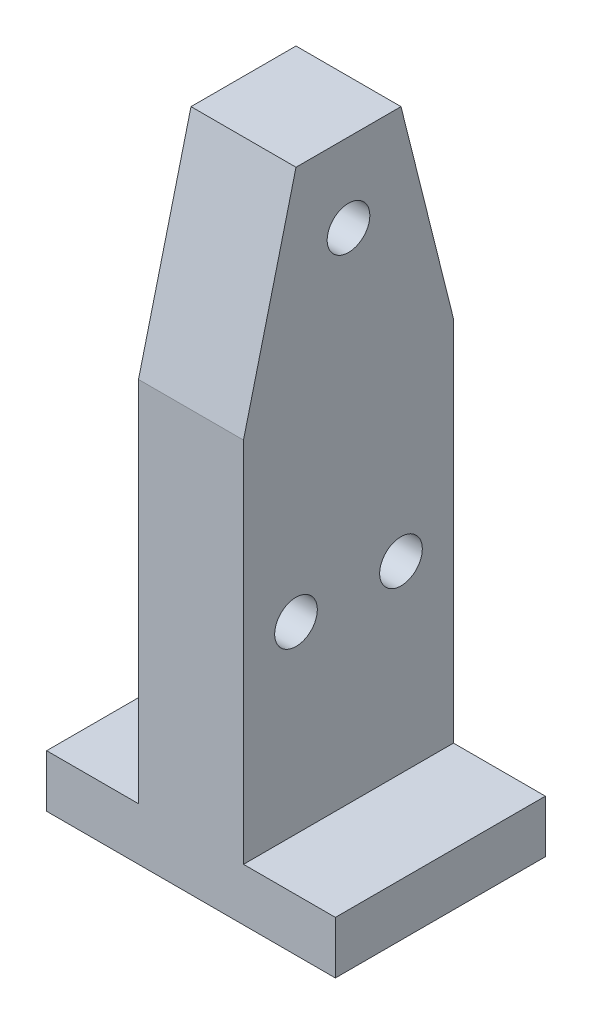
from build123d import *

# Parameters (mm, degrees)
SKETCH27_W                 = 69.85
SKETCH27_H                 = 152.4
BOSS_EXTRUDE4_DEPTH        = 25.4
SKETCH28_W                 = 22.225
SKETCH28_H                 = 139.7
CUT_EXTRUDE5_DEPTH         = 26.4
SKETCH30_OUTSIDE_W         = 87.834
SKETCH30_OUTSIDE_H         = 189.434
CUT_EXTRUDE6_DEPTH         = 35.925
CUT_EXTRUDE6_DEPTH_BACK    = 35.925
F_3_8_CLEARANCE_HOLE4_D    = 10.31748
AUXILIARY_MOUNTING_HOLES_D = 10.31748


with BuildPart() as part:
    # Sketch27 → Boss-Extrude4 (new body, symmetric)
    with BuildSketch(Plane.XY):
        Rectangle(SKETCH27_W, SKETCH27_H)
    extrude(amount=BOSS_EXTRUDE4_DEPTH, both=True)

    # Sketch28 → Cut-Extrude5 (cut, symmetric)
    with BuildSketch(Plane.XY):
        with Locations((23.8125, 6.35)):
            Rectangle(SKETCH28_W, SKETCH28_H)
    cut_extrude5 = extrude(amount=CUT_EXTRUDE5_DEPTH, both=True, mode=Mode.SUBTRACT)

    # Mirror1: Cut-Extrude5 across plane
    add(cut_extrude5.mirror(Plane(origin=(0, 0, 0), x_dir=(0, 0, 1), z_dir=(1, 0, 0))), mode=Mode.SUBTRACT)

    # Sketch30 outside → Cut-Extrude6 (cut, two sides)
    with BuildSketch(Plane(origin=(0, 0, 0), x_dir=(0, 0, -1), z_dir=(1, 0, 0))) as cut_extrude6_sk:
        Rectangle(SKETCH30_OUTSIDE_W, SKETCH30_OUTSIDE_H)
        Polygon((-25.4, 25.4), (-25.4, -76.2), (25.4, -76.2), (25.4, 25.4), (12.7, 76.2), (-12.7, 76.2), align=None, mode=Mode.SUBTRACT)
    extrude(amount=CUT_EXTRUDE6_DEPTH, mode=Mode.SUBTRACT)
    extrude(cut_extrude6_sk.sketch, amount=-CUT_EXTRUDE6_DEPTH_BACK, mode=Mode.SUBTRACT)

    # 3/8 Clearance Hole4 (through all)
    with Locations(Plane.ZY.offset(34.925)):
        with Locations((25.4, 82.55), (0, 57.15)):
            Hole(F_3_8_CLEARANCE_HOLE4_D / 2)

    # Auxiliary Mounting Holes (through all)
    with Locations(Plane(origin=(12.7, 0, 0), x_dir=(0, 0, -1), z_dir=(1, 0, 0))):
        with Locations((-12.7, -19.05), (12.7, -19.05)):
            Hole(AUXILIARY_MOUNTING_HOLES_D / 2)


solid = part.part
